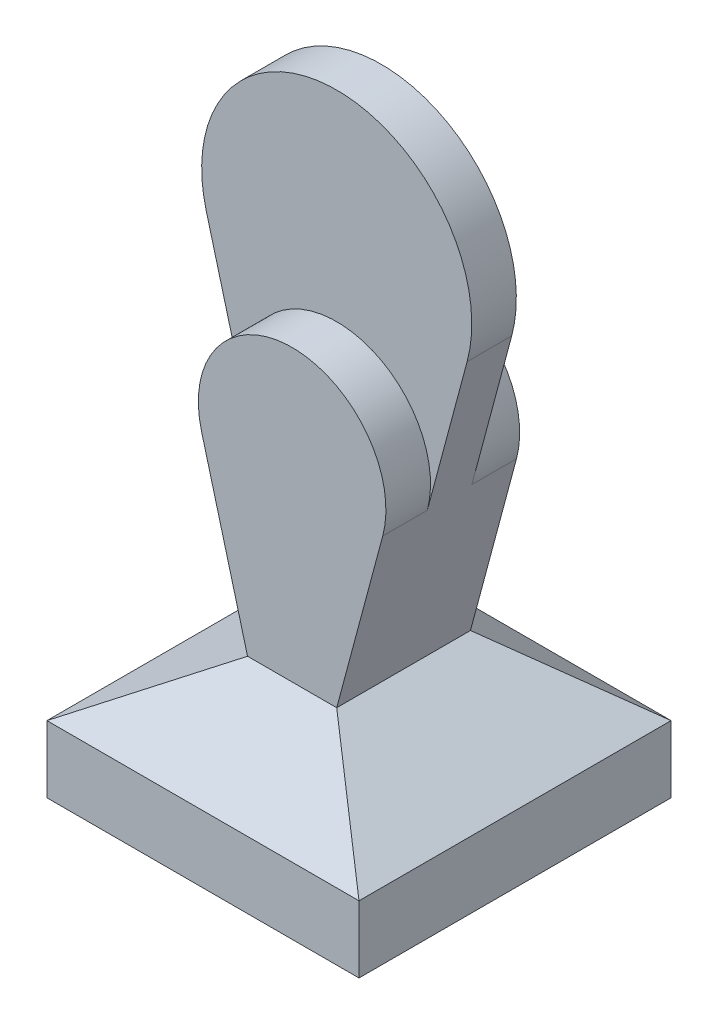
from build123d import *

# Parameters (mm, degrees)
SKETCH1_W      = 70
SKETCH1_H      = 70
EXTRUDE1_DEPTH = 15
SKETCH2_W      = 70
SKETCH2_H      = 70
SKETCH3_W      = 20
SKETCH3_H      = 30
EXTRUDE2_DEPTH = 5
EXTRUDE3_DEPTH = 15


with BuildPart() as part:
    # Sketch1 → Extrude1 (new body)
    with BuildSketch(Plane(origin=(0, 0, 0), x_dir=(1, 0, 0), z_dir=(0, 1, 0))):
        Rectangle(SKETCH1_W, SKETCH1_H)
    extrude(amount=EXTRUDE1_DEPTH)

    # Sketch2 → Loft1 section 0
    with BuildSketch(Plane(origin=(0, 15, 0), x_dir=(-1, 0, 0), z_dir=(0, 1, 0))):
        Rectangle(SKETCH2_W, SKETCH2_H)
    # Sketch3 → Loft1 section 1
    with BuildSketch(Plane(origin=(0, 30, 0), x_dir=(-1, 0, 0), z_dir=(0, 1, 0))):
        Rectangle(SKETCH3_W, SKETCH3_H)
    loft()

    # Sketch4 → Extrude2 (add, symmetric)
    with BuildSketch(Plane.XY):
        with BuildLine():
            Line((10, 30), (29.257681763, 101.870646776))
            ThreePointArc((29.257681763, 101.870646776), (0, 140), (-29.257681763, 101.870646776))
            Line((-29.257681763, 101.870646776), (-10, 30))
            Line((-10, 30), (10, 30))
        make_face()
    extrude(amount=EXTRUDE2_DEPTH, both=True)

    # Sketch5 → Extrude3 (add, symmetric)
    with BuildSketch(Plane.XY):
        with BuildLine():
            Line((20.320734039, 68.517503805), (10, 30))
            Line((10, 30), (-10, 30))
            Line((-10, 30), (-20.320734039, 68.517503805))
            ThreePointArc((-20.320734039, 68.517503805), (0, 95), (20.320734039, 68.517503805))
        make_face()
    extrude(amount=EXTRUDE3_DEPTH, both=True)


solid = part.part
